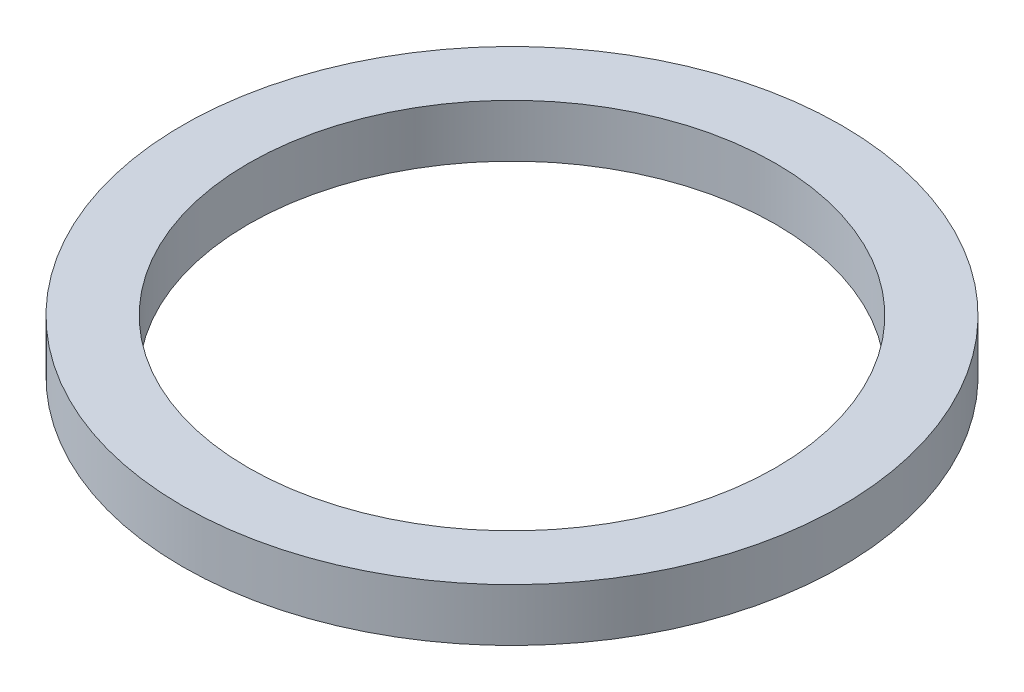
from build123d import *

# Parameters (mm, degrees)
ESQUISSE1_R        = 18.75
ESQUISSE1_R_2      = 15
BOSS_EXTRU_1_DEPTH = 3


with BuildPart() as part:
    # Esquisse1 → Boss.-Extru.1 (new body)
    with BuildSketch(Plane(origin=(0, 0, 0), x_dir=(1, 0, 0), z_dir=(0, 1, 0))):
        with Locations(Location((0, 0, 0), (0, 0, 270))):  # turned: the seam where the file's is
            Circle(ESQUISSE1_R)
        with Locations(Location((0, 0, 0), (0, 0, 270))):  # turned: the seam where the file's is
            Circle(ESQUISSE1_R_2, mode=Mode.SUBTRACT)
    extrude(amount=BOSS_EXTRU_1_DEPTH)


solid = part.part
